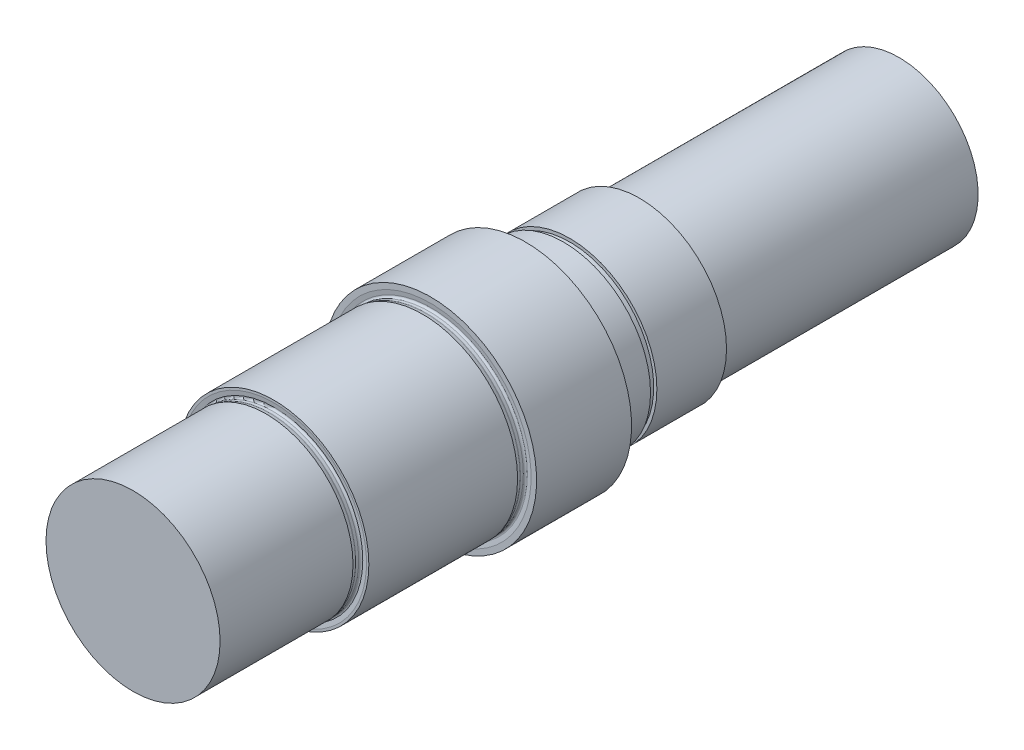
from build123d import *

# Parameters (mm, degrees)
NUT_W = 2
NUT_H = 1


with BuildPart() as part:
    # Au_enkontur → Rotation_GK (revolve)
    with BuildSketch(Plane(origin=(0, 0, 0), x_dir=(0, 0, -1), z_dir=(1, 0, 0)), mode=Mode.PRIVATE) as rotation_gk_sk:
        Polygon((0, 0), (0, 27.5), (44.5, 27.5), (44.5, 30), (94, 30), (94, 33.5), (124, 33.5), (124, 27.5), (160, 27.5), (160, 25), (242, 25), (242, 0), align=None)
    revolve(rotation_gk_sk.sketch.rotate(Axis((0, 0, -88.99), (0, 0, 1)), 90), axis=Axis((0, 0, -88.99), (0, 0, 1)))  # turned: the seam where the file's is

    # Freistich 1 → Schnitt-Rotation_Freistich 1 (revolve, cut)
    with BuildSketch(Plane(origin=(0, 0, 0), x_dir=(0, 0, -1), z_dir=(1, 0, 0)), mode=Mode.PRIVATE) as schnitt_rotation_freistich_1_sk:
        with BuildLine():
            Line((42, 27.5), (43.043315314, 27.220444504))
            ThreePointArc((43.043315314, 27.220444504), (43.120291025, 27.205133083), (43.198606741, 27.2))
            Line((43.198606741, 27.2), (44.1, 27.2))
            ThreePointArc((44.1, 27.2), (44.552825748, 27.406364583), (44.694160841, 27.883503861))
            Line((44.694160841, 27.883503861), (44.5, 29.265030032))
            Line((44.5, 29.265030032), (42, 29.265030032))
            Line((42, 29.265030032), (42, 27.5))
        make_face()
    revolve(schnitt_rotation_freistich_1_sk.sketch.rotate(Axis((0, 0, -88.99), (0, 0, 1)), 90), axis=Axis((0, 0, -88.99), (0, 0, 1)), mode=Mode.SUBTRACT)  # turned: the seam where the file's is

    # Freistich 2 → Schnitt-Rotation_Freistich 2 (revolve, cut)
    with BuildSketch(Plane(origin=(0, 2.5, -49.5), x_dir=(0, 0, -1), z_dir=(1, 0, 0)), mode=Mode.PRIVATE) as schnitt_rotation_freistich_2_sk:
        with BuildLine():
            Line((42, 27.5), (43.043315314, 27.220444504))
            ThreePointArc((43.043315314, 27.220444504), (43.120291025, 27.205133083), (43.198606741, 27.2))
            Line((43.198606741, 27.2), (44.1, 27.2))
            ThreePointArc((44.1, 27.2), (44.552825748, 27.406364583), (44.694160841, 27.883503861))
            Line((44.694160841, 27.883503861), (44.5, 29.265030032))
            Line((44.5, 29.265030032), (42, 29.265030032))
            Line((42, 29.265030032), (42, 27.5))
        make_face()
    revolve(schnitt_rotation_freistich_2_sk.sketch.rotate(Axis((0, 0, -88.99), (0, 0, 1)), 90), axis=Axis((0, 0, -88.99), (0, 0, 1)), mode=Mode.SUBTRACT)  # turned: the seam where the file's is

    # Freistich 3 → Schnitt-Rotation_Freistich 3 (revolve, cut)
    with BuildSketch(Plane(origin=(0, 0, -168.5), x_dir=(0, 0, 1), z_dir=(-1, 0, 0)), mode=Mode.PRIVATE) as schnitt_rotation_freistich_3_sk:
        with BuildLine():
            Line((42, 27.5), (43.043315314, 27.220444504))
            ThreePointArc((43.043315314, 27.220444504), (43.120291025, 27.205133083), (43.198606741, 27.2))
            Line((43.198606741, 27.2), (44.1, 27.2))
            ThreePointArc((44.1, 27.2), (44.552825748, 27.406364583), (44.694160841, 27.883503861))
            Line((44.694160841, 27.883503861), (44.5, 29.265030032))
            Line((44.5, 29.265030032), (42, 29.265030032))
            Line((42, 29.265030032), (42, 27.5))
        make_face()
    revolve(schnitt_rotation_freistich_3_sk.sketch.rotate(Axis((0, 0, -88.99), (0, 0, 1)), 90), axis=Axis((0, 0, -88.99), (0, 0, 1)), mode=Mode.SUBTRACT)  # turned: the seam where the file's is

    # Nut → Schnitt-Rotation_Nut (revolve, cut)
    with BuildSketch(Plane(origin=(0, 0, 0), x_dir=(0, 0, -1), z_dir=(1, 0, 0)), mode=Mode.PRIVATE) as schnitt_rotation_nut_sk:
        with Locations((137, 27)):
            Rectangle(NUT_W, NUT_H)
    revolve(schnitt_rotation_nut_sk.sketch.rotate(Axis((0, 0, -88.99), (0, 0, 1)), 90), axis=Axis((0, 0, -88.99), (0, 0, 1)), mode=Mode.SUBTRACT)  # turned: the seam where the file's is


solid = part.part
